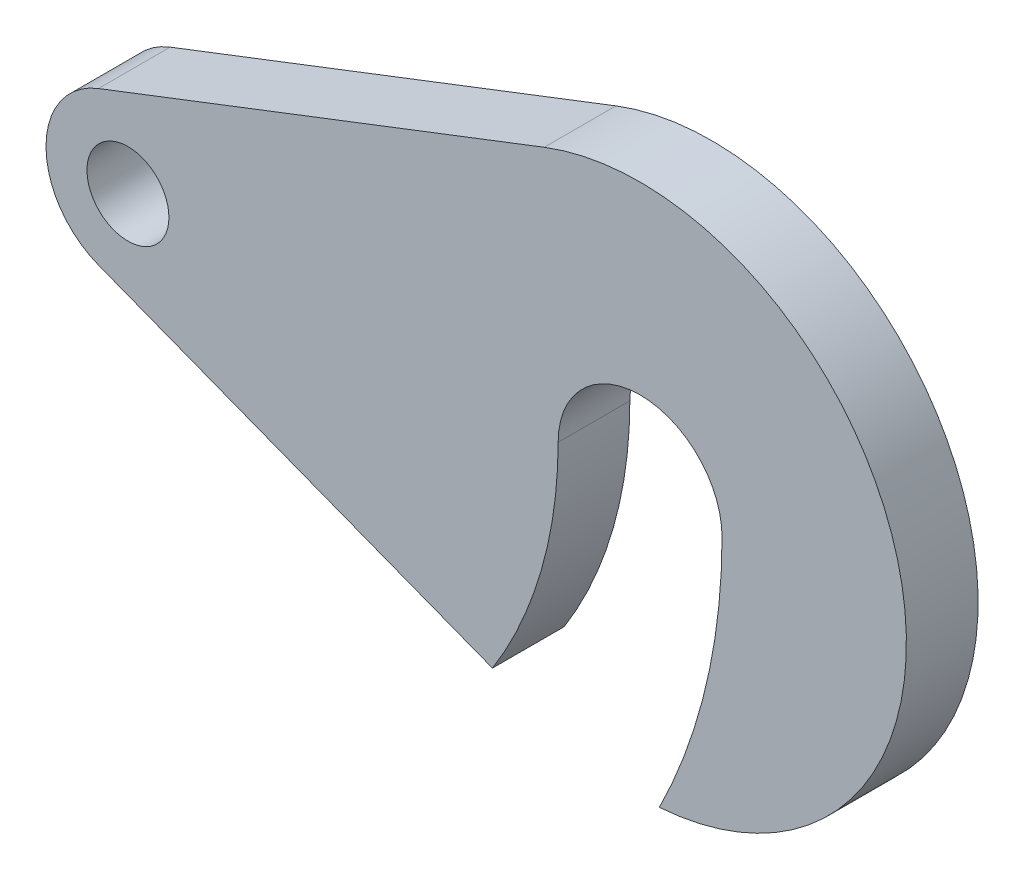
from build123d import *

# Parameters (mm, degrees)
SKICA2_R                = 4
P_IDAT_VYSUNUT_M1_DEPTH = 7


with BuildPart() as part:
    # Skica2 → Přidat vysunutím1 (new body)
    with BuildSketch(Plane.XY):
        with BuildLine():
            Line((-52.88, 7.463618425), (-9.36, 24.256759883))
            ThreePointArc((-9.36, 24.256759883), (25.371520283, 5.682073435), (1.88, -25.931941694))
            ThreePointArc((1.88, -25.931941694), (6.44926926, -13.322161987), (8, 0))
            ThreePointArc((8, 0), (0, 8), (-8, 0))
            ThreePointArc((-8, 0), (-9.635178846, -11.60522353), (-14.413391103, -22.306798678))
            Line((-14.413391103, -22.306798678), (-52.88, -7.463618425))
            ThreePointArc((-52.88, -7.463618425), (-58, 0), (-52.88, 7.463618425))
        make_face()
        with Locations((-50, 0)):
            Circle(SKICA2_R, mode=Mode.SUBTRACT)
    extrude(amount=P_IDAT_VYSUNUT_M1_DEPTH)


solid = part.part
